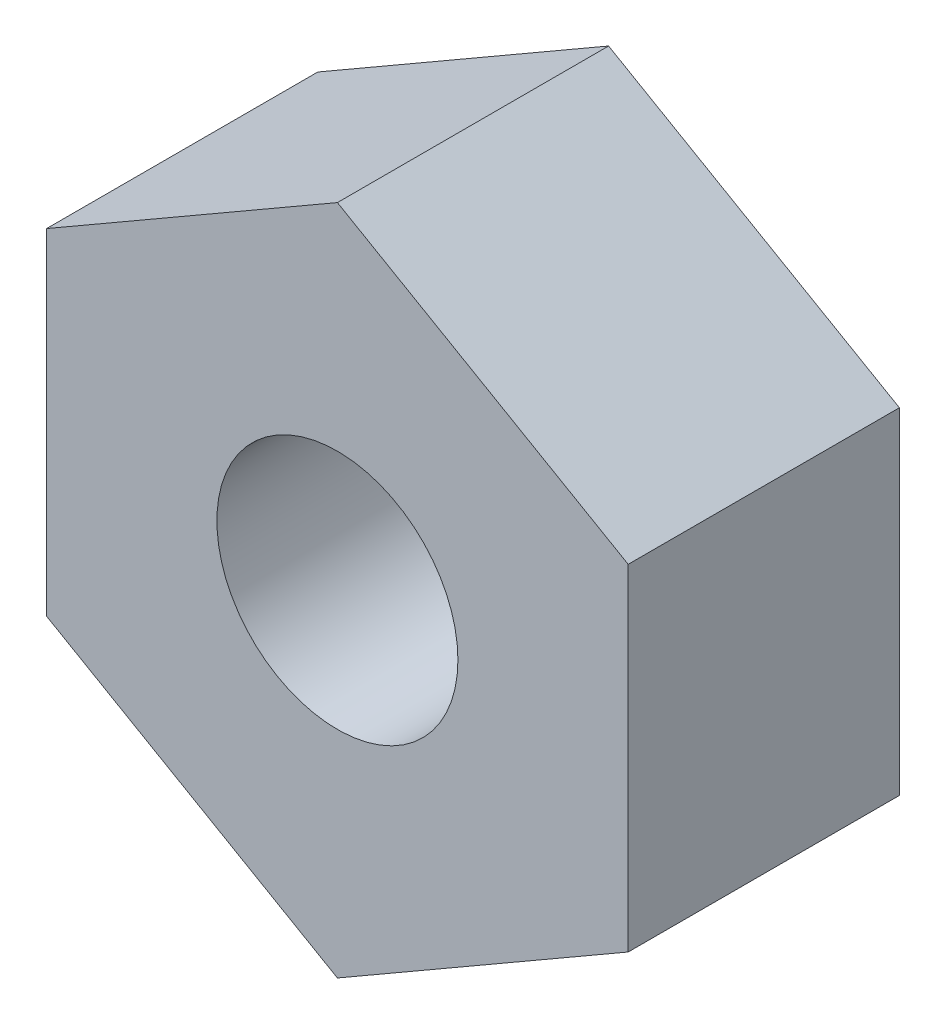
from build123d import *

# Parameters (mm, degrees)
SKETCH1_R           = 4
BOSS_EXTRUDE1_DEPTH = 4.5


with BuildPart() as part:
    # Sketch1 → Boss-Extrude1 (new body, symmetric)
    with BuildSketch(Plane.XY):
        Polygon((0, 11.142860195), (-9.65, 5.571430098), (-9.65, -5.571430098), (0, -11.142860195), (9.65, -5.571430098), (9.65, 5.571430098), align=None)
        Circle(SKETCH1_R, mode=Mode.SUBTRACT)
    extrude(amount=BOSS_EXTRUDE1_DEPTH, both=True)


solid = part.part
